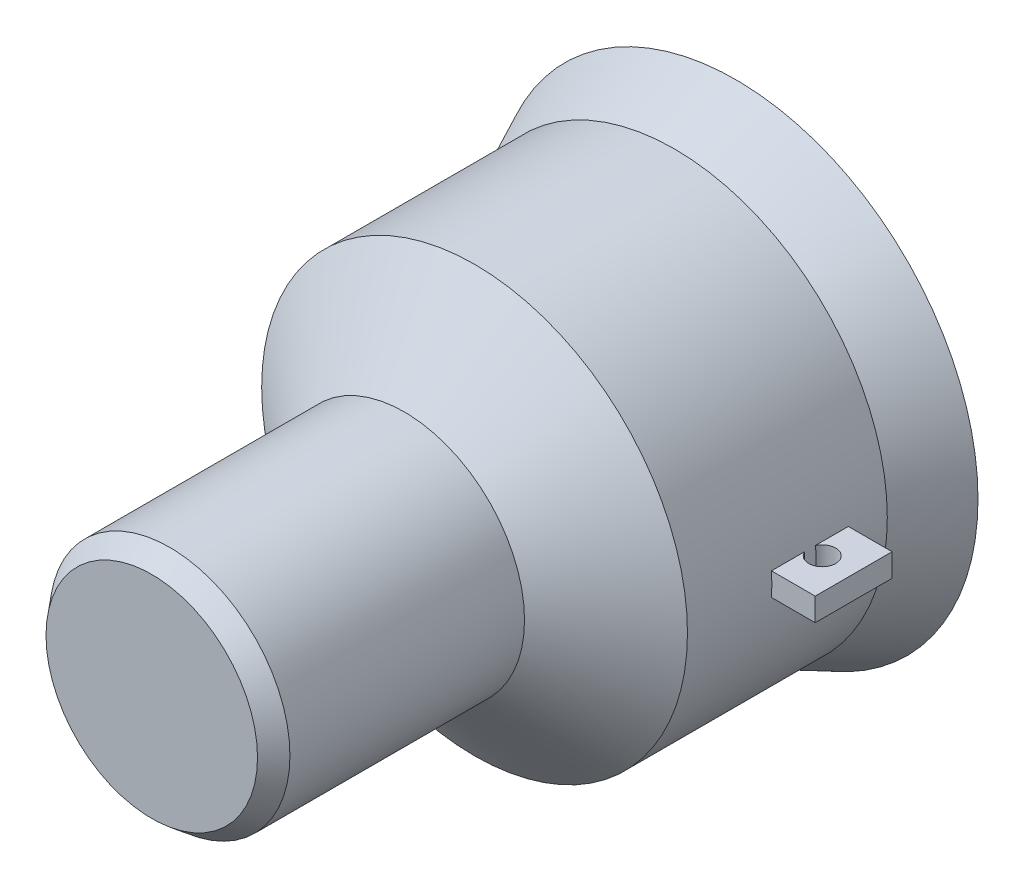
from build123d import *

# Parameters (mm, degrees)
EXTRUDE_1_DEPTH      = 1.5
EXTRUDE_1_DEPTH_BACK = 1.5
SKETCH_2_W           = 8.167130209
SKETCH_2_H           = 10
SKETCH_2_R           = 1.75


with BuildPart() as part:
    # 草图1 → 旋转1 (revolve)
    with BuildSketch(Plane(origin=(0, 0, 0), x_dir=(1, 0, 0), z_dir=(0, 1, 0))):
        Polygon((25.35, 72.313545186), (31.5, 72.313545186), (27.7, 64.313545186), (27.7, 38.313545186), (15.641285641, 29.17200386), (15.641285641, -1.349457697), (13.76021029, -3.686454814), (0, -3.686454814), (0, 28.127467739), (13, 28.127467739), (25.35, 38.313545186), align=None)
    revolve(axis=Axis((0, 0, 0), (0, 0, -1)))

    # 草图2 → 凸台-拉伸1 (add, two sides: drawn at the far end of the back side and taken through both)
    # profile 1 of 2: a face of its own
    with BuildSketch(Plane(origin=(0, 0, 0), x_dir=(1, 0, 0), z_dir=(0, 1, 0)).offset(-EXTRUDE_1_DEPTH_BACK)):
        with Locations((29.266434896, 54.282588322)):
            Rectangle(SKETCH_2_W, SKETCH_2_H)
        with Locations((29.266434895, 54.282588322)):
            Circle(SKETCH_2_R, mode=Mode.SUBTRACT)
    # profile 2 of 2: a face of its own
    with BuildSketch(Plane(origin=(0, 0, 0), x_dir=(1, 0, 0), z_dir=(0, 1, 0)).offset(-EXTRUDE_1_DEPTH_BACK)):
        with Locations((-29.266434896, 54.282588322)):
            Rectangle(SKETCH_2_W, SKETCH_2_H)
        with Locations((-29.266434895, 54.282588322)):
            Circle(SKETCH_2_R, mode=Mode.SUBTRACT)
    extrude(amount=EXTRUDE_1_DEPTH + EXTRUDE_1_DEPTH_BACK)


solid = part.part
